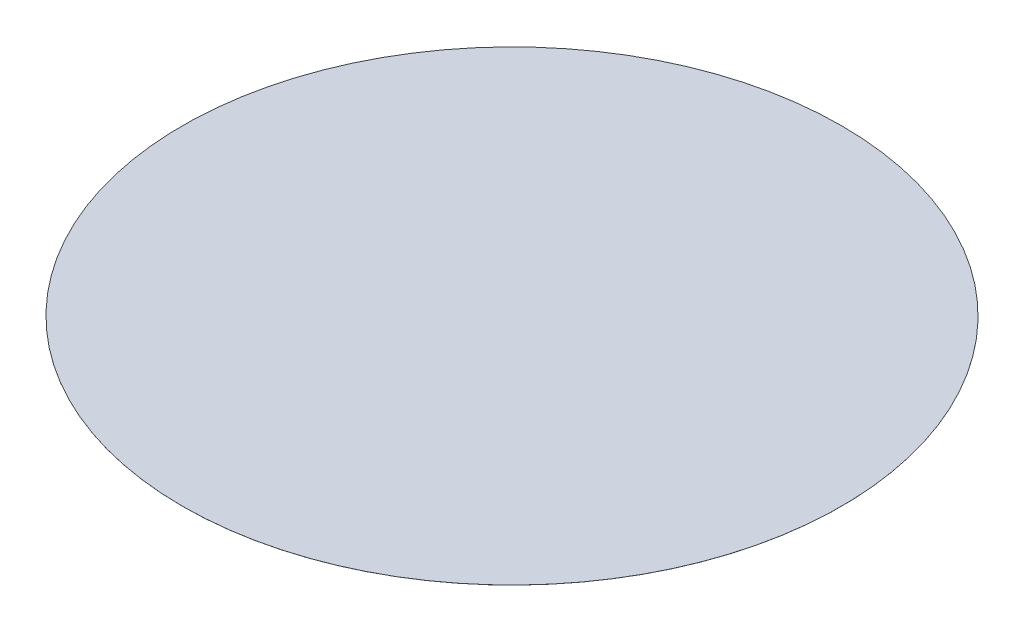
from build123d import *

# Parameters (mm, degrees)
SKETCH1_R           = 10.65
BOSS_EXTRUDE1_DEPTH = 15.5
BOSS_EXTRUDE4_START = 1
SKETCH4_R           = 63.5
BOSS_EXTRUDE4_DEPTH = 0.01


with BuildPart() as part:
    # Sketch1 → Boss-Extrude1 (new body)
    with BuildSketch(Plane(origin=(0, 0, 0), x_dir=(1, 0, 0), z_dir=(0, 1, 0))):
        Circle(SKETCH1_R)
    extrude(amount=BOSS_EXTRUDE1_DEPTH)


with BuildPart() as body_2:
    # Sketch4 → Boss-Extrude4 (new body)
    with BuildSketch(Plane(origin=(0, 15.5, 0), x_dir=(1, 0, 0), z_dir=(0, 1, 0)).offset(BOSS_EXTRUDE4_START)):
        Circle(SKETCH4_R)
    extrude(amount=BOSS_EXTRUDE4_DEPTH)


solid = Compound([part.part, body_2.part])
